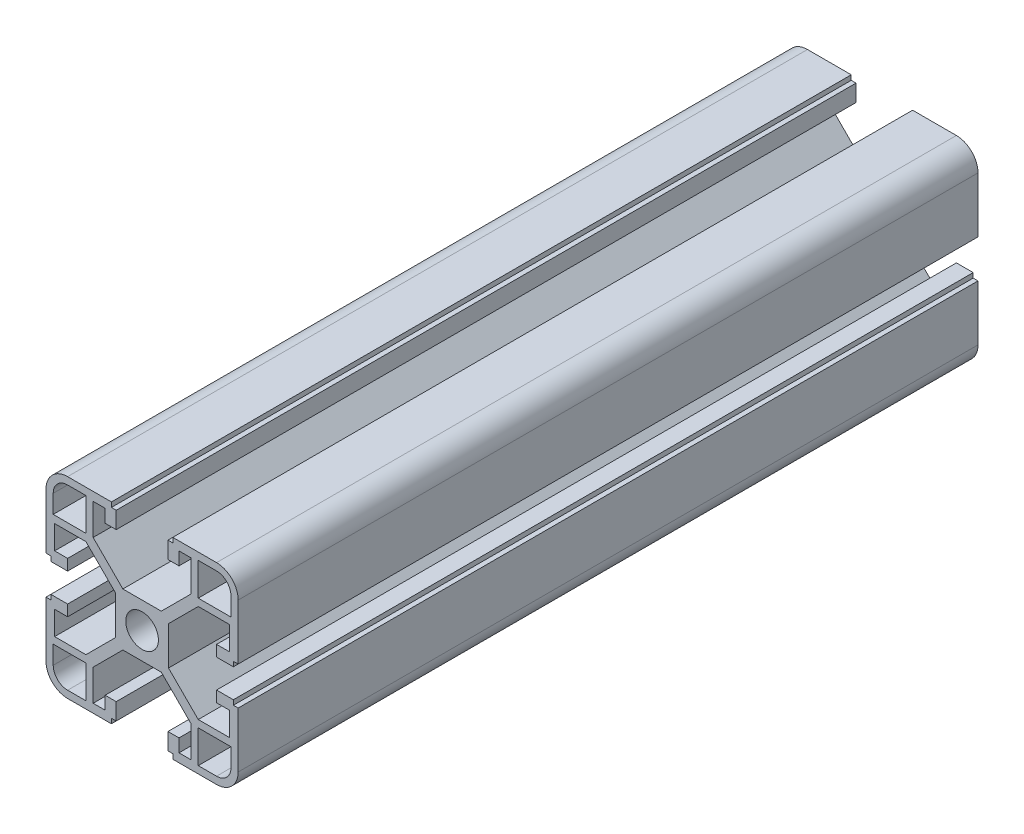
from build123d import *

# Parameters (mm, degrees)
BOSS_EXTRUDE1_DEPTH  = 154
MIRROR3_COPY_1_DEPTH = 154
MIRROR3_COPY_2_DEPTH = 154


with BuildPart() as part:
    # Sketch1 → Boss-Extrude1 (new body)
    with BuildSketch(Plane.XY):
        with BuildLine():
            Line((3.4, 0), (5.5, 0))
            Line((5.5, 0), (5.5, 4))
            Line((5.5, 4), (11.69, 10.19))
            Line((11.69, 10.19), (18.2, 10.19))
            Line((18.2, 10.19), (18.2, 5.265595036))
            Line((18.2, 5.265595036), (15.5, 5.265595036))
            Line((15.5, 5.265595036), (15.5, 2.965595036))
            Line((15.5, 2.965595036), (19, 2.965595036))
            Line((19, 2.965595036), (19, 3.965595036))
            Line((19, 3.965595036), (20, 3.965595036))
            Line((20, 3.965595036), (20, 15.5))
            ThreePointArc((20, 15.5), (18.681980515, 18.681980515), (15.5, 20))
            Line((15.5, 20), (6.385304712, 20))
            Line((6.385304712, 20), (6.385304712, 19))
            Line((6.385304712, 19), (5.385304712, 19))
            Line((5.385304712, 19), (5.385304712, 15.5))
            Line((5.385304712, 15.5), (7.685304712, 15.5))
            Line((7.685304712, 15.5), (7.685304712, 18.2))
            Line((7.685304712, 18.2), (10.19, 18.2))
            Line((10.19, 18.2), (10.19, 11.69))
            Line((10.19, 11.69), (4, 5.5))
            Line((4, 5.5), (0, 5.5))
            Line((0, 5.5), (0, 3.4))
            ThreePointArc((0, 3.4), (2.404163056, 2.404163056), (3.4, 0))
        make_face()
        with BuildLine():
            Line((18.5, 11.69), (18.5, 15.5))
            ThreePointArc((18.5, 15.5), (17.621320344, 17.621320344), (15.5, 18.5))
            Line((15.5, 18.5), (11.69, 18.5))
            Line((11.69, 18.5), (11.69, 11.69))
            Line((11.69, 11.69), (18.5, 11.69))
        make_face(mode=Mode.SUBTRACT)
    boss_extrude1 = extrude(amount=BOSS_EXTRUDE1_DEPTH)

    # Mirror1: Boss-Extrude1 across plane
    add(boss_extrude1.mirror(Plane.ZX))

    # Mirror2: Boss-Extrude1 across plane
    add(boss_extrude1.mirror(Plane(origin=(0, 0, 0), x_dir=(0, 0, 1), z_dir=(1, 0, 0))))

    # Mirror3 copy 1 sketch → Mirror3 copy 1 (add)
    with BuildSketch(Plane(origin=(0, 0, 0), x_dir=(-1, 0, 0), z_dir=(0, 0, 1))):
        with BuildLine():
            Line((3.4, 0), (5.5, 0))
            Line((5.5, 0), (5.5, 4))
            Line((5.5, 4), (11.69, 10.19))
            Line((11.69, 10.19), (18.2, 10.19))
            Line((18.2, 10.19), (18.2, 5.265595036))
            Line((18.2, 5.265595036), (15.5, 5.265595036))
            Line((15.5, 5.265595036), (15.5, 2.965595036))
            Line((15.5, 2.965595036), (19, 2.965595036))
            Line((19, 2.965595036), (19, 3.965595036))
            Line((19, 3.965595036), (20, 3.965595036))
            Line((20, 3.965595036), (20, 15.5))
            ThreePointArc((20, 15.5), (18.681980515, 18.681980515), (15.5, 20))
            Line((15.5, 20), (6.385304712, 20))
            Line((6.385304712, 20), (6.385304712, 19))
            Line((6.385304712, 19), (5.385304712, 19))
            Line((5.385304712, 19), (5.385304712, 15.5))
            Line((5.385304712, 15.5), (7.685304712, 15.5))
            Line((7.685304712, 15.5), (7.685304712, 18.2))
            Line((7.685304712, 18.2), (10.19, 18.2))
            Line((10.19, 18.2), (10.19, 11.69))
            Line((10.19, 11.69), (4, 5.5))
            Line((4, 5.5), (0, 5.5))
            Line((0, 5.5), (0, 3.4))
            ThreePointArc((0, 3.4), (2.404163056, 2.404163056), (3.4, 0))
        make_face()
        with BuildLine():
            Line((18.5, 11.69), (18.5, 15.5))
            ThreePointArc((18.5, 15.5), (17.621320344, 17.621320344), (15.5, 18.5))
            Line((15.5, 18.5), (11.69, 18.5))
            Line((11.69, 18.5), (11.69, 11.69))
            Line((11.69, 11.69), (18.5, 11.69))
        make_face(mode=Mode.SUBTRACT)
    extrude(amount=MIRROR3_COPY_1_DEPTH)

    # Mirror3 copy 2 sketch → Mirror3 copy 2 (add)
    with BuildSketch(Plane.XY):
        with BuildLine():
            Line((3.4, 0), (5.5, 0))
            Line((5.5, 0), (5.5, -4))
            Line((5.5, -4), (11.69, -10.19))
            Line((11.69, -10.19), (18.2, -10.19))
            Line((18.2, -10.19), (18.2, -5.265595036))
            Line((18.2, -5.265595036), (15.5, -5.265595036))
            Line((15.5, -5.265595036), (15.5, -2.965595036))
            Line((15.5, -2.965595036), (19, -2.965595036))
            Line((19, -2.965595036), (19, -3.965595036))
            Line((19, -3.965595036), (20, -3.965595036))
            Line((20, -3.965595036), (20, -15.5))
            ThreePointArc((20, -15.5), (18.681980515, -18.681980515), (15.5, -20))
            Line((15.5, -20), (6.385304712, -20))
            Line((6.385304712, -20), (6.385304712, -19))
            Line((6.385304712, -19), (5.385304712, -19))
            Line((5.385304712, -19), (5.385304712, -15.5))
            Line((5.385304712, -15.5), (7.685304712, -15.5))
            Line((7.685304712, -15.5), (7.685304712, -18.2))
            Line((7.685304712, -18.2), (10.19, -18.2))
            Line((10.19, -18.2), (10.19, -11.69))
            Line((10.19, -11.69), (4, -5.5))
            Line((4, -5.5), (0, -5.5))
            Line((0, -5.5), (0, -3.4))
            ThreePointArc((0, -3.4), (2.404163056, -2.404163056), (3.4, 0))
        make_face()
        with BuildLine():
            Line((18.5, -11.69), (18.5, -15.5))
            ThreePointArc((18.5, -15.5), (17.621320344, -17.621320344), (15.5, -18.5))
            Line((15.5, -18.5), (11.69, -18.5))
            Line((11.69, -18.5), (11.69, -11.69))
            Line((11.69, -11.69), (18.5, -11.69))
        make_face(mode=Mode.SUBTRACT)
    extrude(amount=MIRROR3_COPY_2_DEPTH)


solid = part.part
